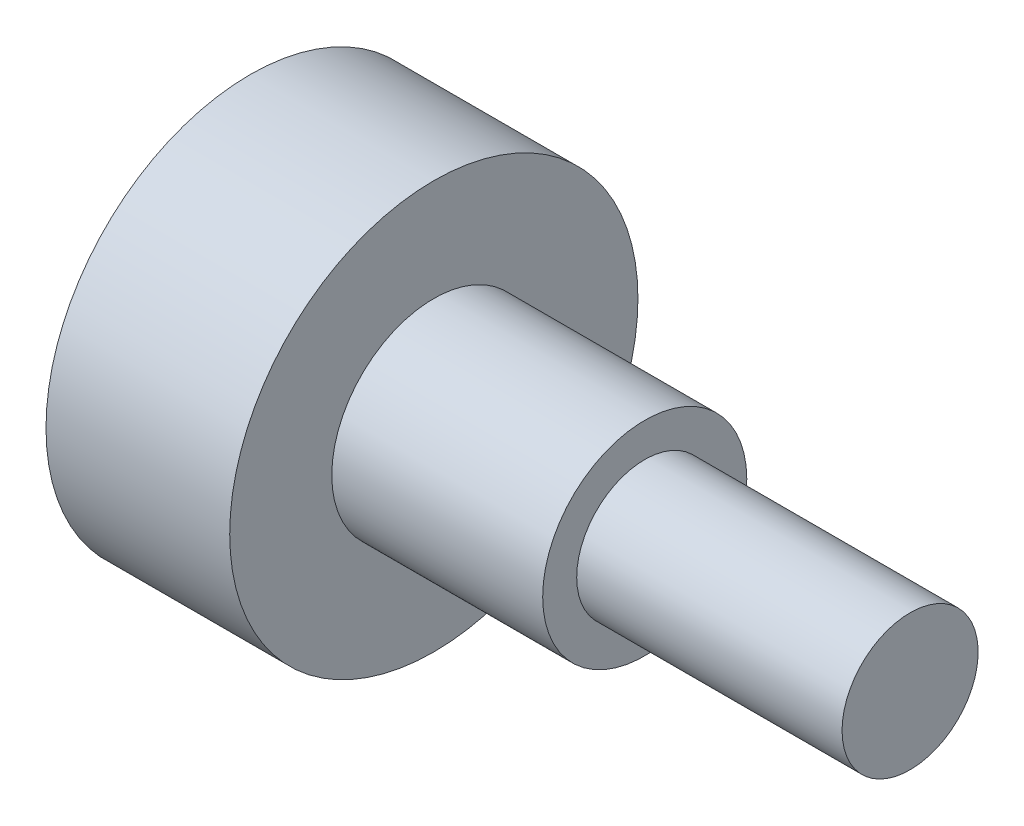
from build123d import *

# Parameters (mm, degrees)
SCHNITT_LINEAR_AUSTRAGEN1_DEPTH = 2.7
SKIZZE3_W                       = 7
SKIZZE3_H                       = 2.1
SKIZZE4_W                       = 3.9
SKIZZE4_H                       = 0.5


with BuildPart() as part:
    # Skizze1 → Rotation1 (revolve)
    with BuildSketch(Plane.XY):
        Polygon((-4, 0), (7, 0), (7, 2), (0, 2), (0, 3.6), (-4, 3.6), align=None)
    revolve(axis=Axis((-29.304407472, 0, 0), (1, 0, 0)))

    # Skizze2 → Schnitt-Linear austragen1 (cut)
    with BuildSketch(Plane.ZY.offset(4)):
        Polygon((0, 1.732050808), (-1.5, 0.866025404), (-1.5, -0.866025404), (0, -1.732050808), (1.5, -0.866025404), (1.5, 0.866025404), align=None)
    extrude(amount=-SCHNITT_LINEAR_AUSTRAGEN1_DEPTH, mode=Mode.SUBTRACT)

    # Skizze3 → Schnitt-Rotation1 (revolve, cut)
    with BuildSketch(Plane.XY):
        with Locations((3.5, 2.55)):
            Rectangle(SKIZZE3_W, SKIZZE3_H)
    revolve(axis=Axis((-0.757628828, 0, 0), (1, 0, 0)), mode=Mode.SUBTRACT)

    # Skizze4 → Schnitt-Rotation2 (revolve, cut)
    with BuildSketch(Plane.XY):
        with Locations((5.05, 1.25)):
            Rectangle(SKIZZE4_W, SKIZZE4_H)
    revolve(axis=Axis((0, 0, 0), (1, 0, 0)), mode=Mode.SUBTRACT)

    # Skizze6 → Schnitt-Rotation3 (revolve, cut)
    with BuildSketch(Plane.XY):
        Polygon((-2.7, 3), (0, 3), (0, 3.6), (-4, 3.6), (-4, 0), (-2.7, 0), align=None)
    revolve(axis=Axis((-4.405632507, 0, 0), (1, 0, 0)), mode=Mode.SUBTRACT)


solid = part.part
